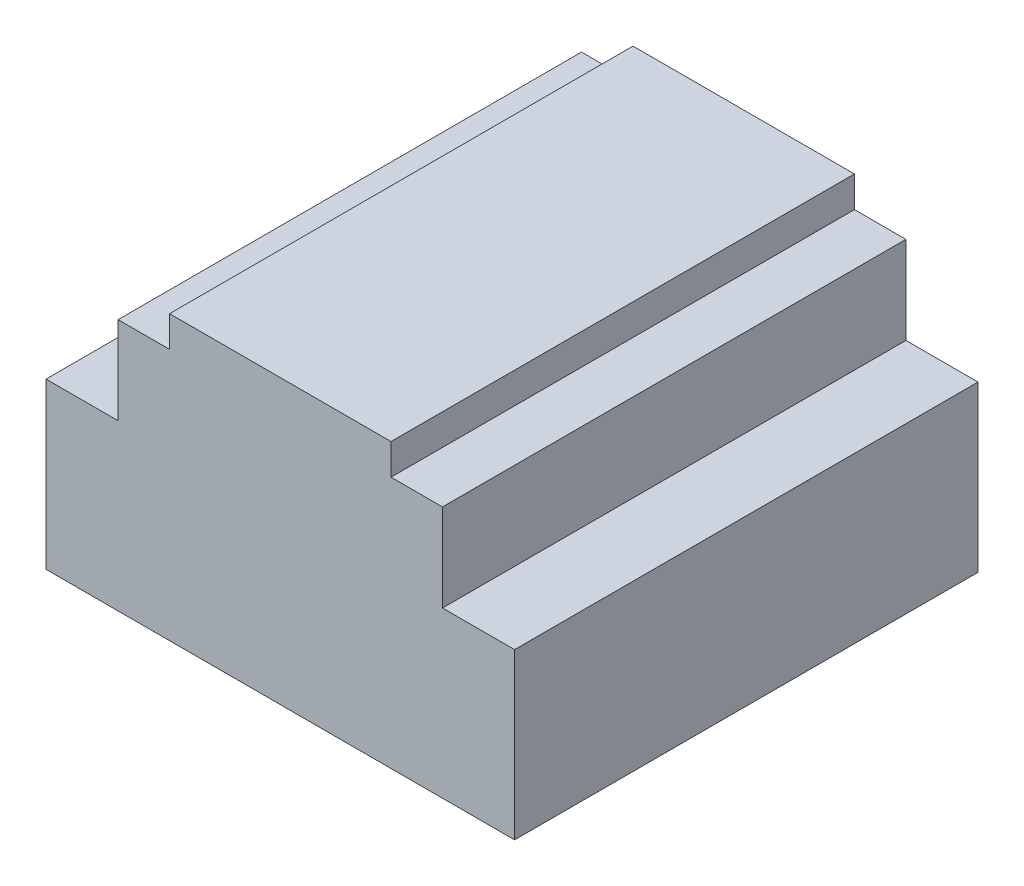
from build123d import *

# Parameters (mm, degrees)
SKETCH1_W           = 91
SKETCH1_H           = 55
BOSS_EXTRUDE1_DEPTH = 90
SKETCH2_W           = 24
SKETCH2_H           = 6
CUT_EXTRUDE1_DEPTH  = 91
SKETCH3_W           = 14
SKETCH3_H           = 17
CUT_EXTRUDE2_DEPTH  = 91


with BuildPart() as part:
    # Sketch1 → Boss-Extrude1 (new body)
    with BuildSketch(Plane.XY):
        with Locations((45.5, 27.5)):
            Rectangle(SKETCH1_W, SKETCH1_H)
    extrude(amount=BOSS_EXTRUDE1_DEPTH)

    # Sketch2 → Cut-Extrude1 (cut, through all)
    with BuildSketch(Plane.XY.offset(90)):
        with Locations((79, 52)):
            Rectangle(SKETCH2_W, SKETCH2_H)
        with Locations((12, 52)):
            Rectangle(SKETCH2_W, SKETCH2_H)
    extrude(amount=-CUT_EXTRUDE1_DEPTH, mode=Mode.SUBTRACT)

    # Sketch3 → Cut-Extrude2 (cut, through all)
    with BuildSketch(Plane.XY.offset(90)):
        with Locations((84, 40.5)):
            Rectangle(SKETCH3_W, SKETCH3_H)
        with Locations((7, 40.5)):
            Rectangle(SKETCH3_W, SKETCH3_H)
    extrude(amount=-CUT_EXTRUDE2_DEPTH, mode=Mode.SUBTRACT)


solid = part.part
